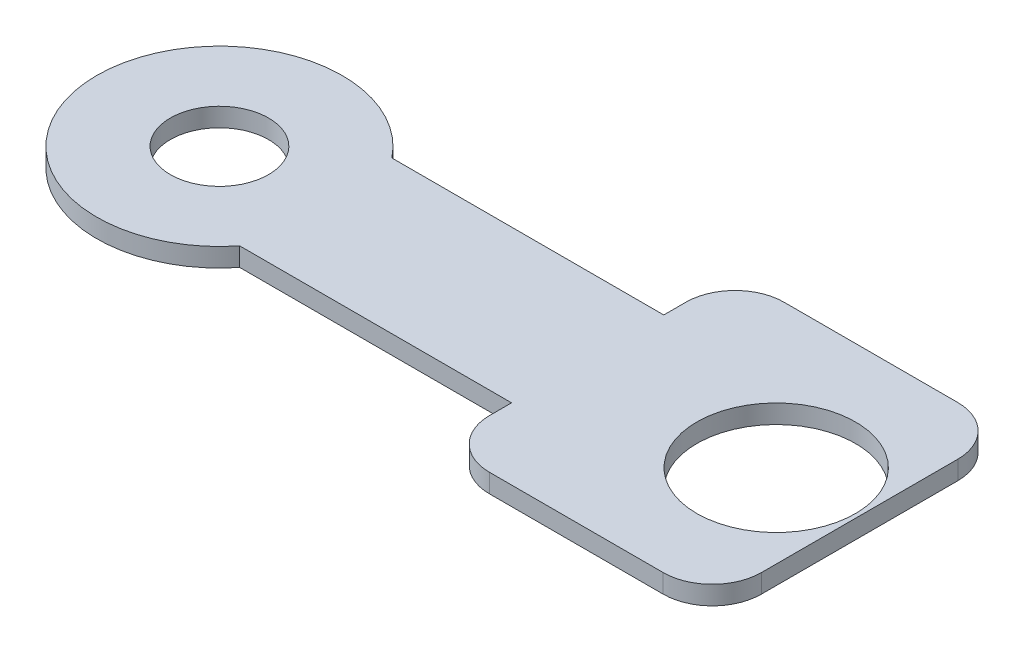
from build123d import *

# Parameters (mm, degrees)
SKETCH1_R           = 1
SKETCH1_R_2         = 1.616439125
BOSS_EXTRUDE4_DEPTH = 0.381


with BuildPart() as part:
    # Sketch1 → Boss-Extrude4 (new body)
    with BuildSketch(Plane(origin=(0, 0, 0), x_dir=(1, 0, 0), z_dir=(0, 1, 0))):
        with BuildLine():
            Line((4.461504525, -1.55), (10, -1.55))
            Line((10, -1.55), (10, -2))
            ThreePointArc((10, -2), (10.292893219, -2.707106781), (11, -3))
            Line((11, -3), (14.538495475, -3))
            ThreePointArc((14.538495475, -3), (15.245602257, -2.707106781), (15.538495475, -2))
            Line((15.538495475, -2), (15.538495475, 2))
            ThreePointArc((15.538495475, 2), (15.245602257, 2.707106781), (14.538495475, 3))
            Line((14.538495475, 3), (11, 3))
            ThreePointArc((11, 3), (10.292893219, 2.707106781), (10, 2))
            Line((10, 2), (10, 1.55))
            Line((10, 1.55), (4.461504525, 1.55))
            ThreePointArc((4.461504525, 1.55), (0, 0), (4.461504525, -1.55))
        make_face()
        with Locations((2.5, 0)):
            Circle(SKETCH1_R, mode=Mode.SUBTRACT)
        with Locations((13.839657546, 0)):
            Circle(SKETCH1_R_2, mode=Mode.SUBTRACT)
    extrude(amount=BOSS_EXTRUDE4_DEPTH)


solid = part.part
